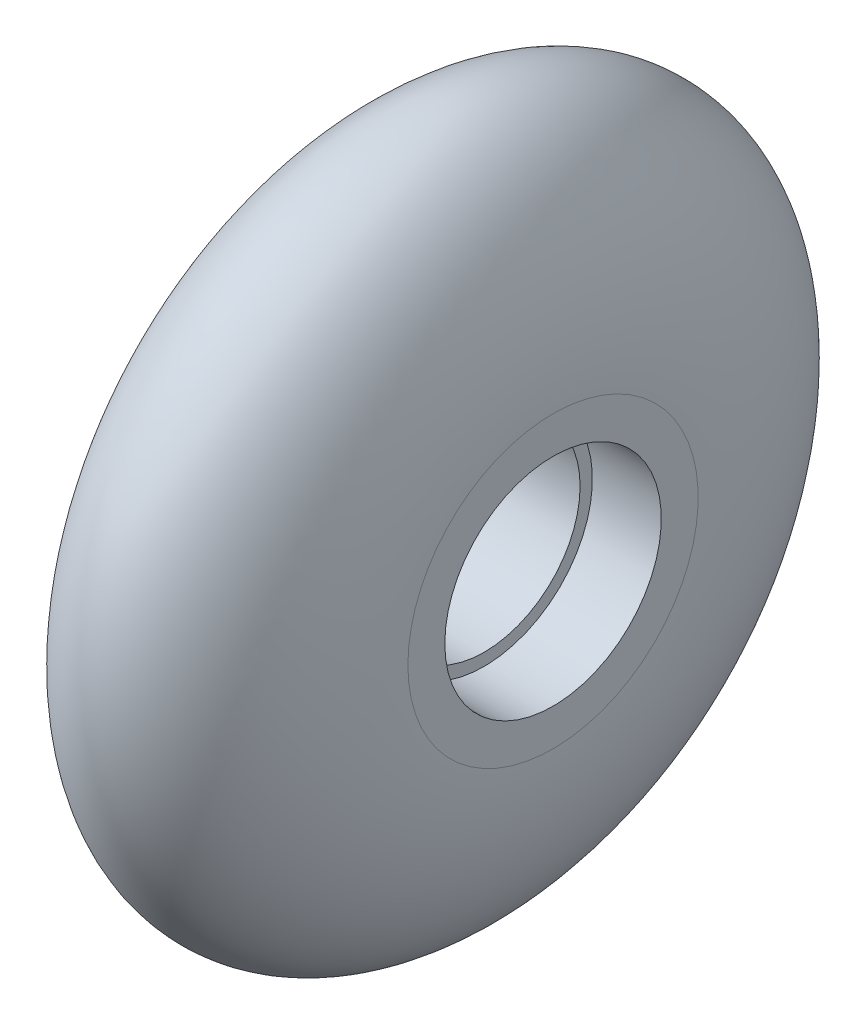
from build123d import *

# Parameters (mm, degrees)
SKETCH2_R          = 11
CUT_EXTRUDE1_DEPTH = 7


with BuildPart() as part:
    # Sketch1 → Revolve1 (revolve)
    with BuildSketch(Plane.XY):
        with BuildLine():
            Line((0, 9.75), (0, 14.75))
            add(Edge.make_bspline(
                [(24.4, 14.75), (24.4, 36), (12.2, 36), (0, 36), (0, 14.75)],
                knots=[1.570796327, 1.570796327, 1.570796327, 3.141592654, 3.141592654, 4.71238898, 4.71238898, 4.71238898], degree=2, weights=[1, 0.707106781, 1, 0.707106781, 1]))
            Line((24.4, 14.75), (24.4, 9.75))
            Line((24.4, 9.75), (0, 9.75))
        make_face()
    revolve(axis=Axis((0, 0, 0), (1, 0, 0)))

    # Sketch2 → Cut-Extrude1 (cut)
    with BuildSketch(Plane.ZY):
        Circle(SKETCH2_R)
    cut_extrude1 = extrude(amount=-CUT_EXTRUDE1_DEPTH, mode=Mode.SUBTRACT)

    # Mirror1: Cut-Extrude1 across plane
    add(cut_extrude1.mirror(Plane.ZY.offset(-12.2)), mode=Mode.SUBTRACT)


solid = part.part
